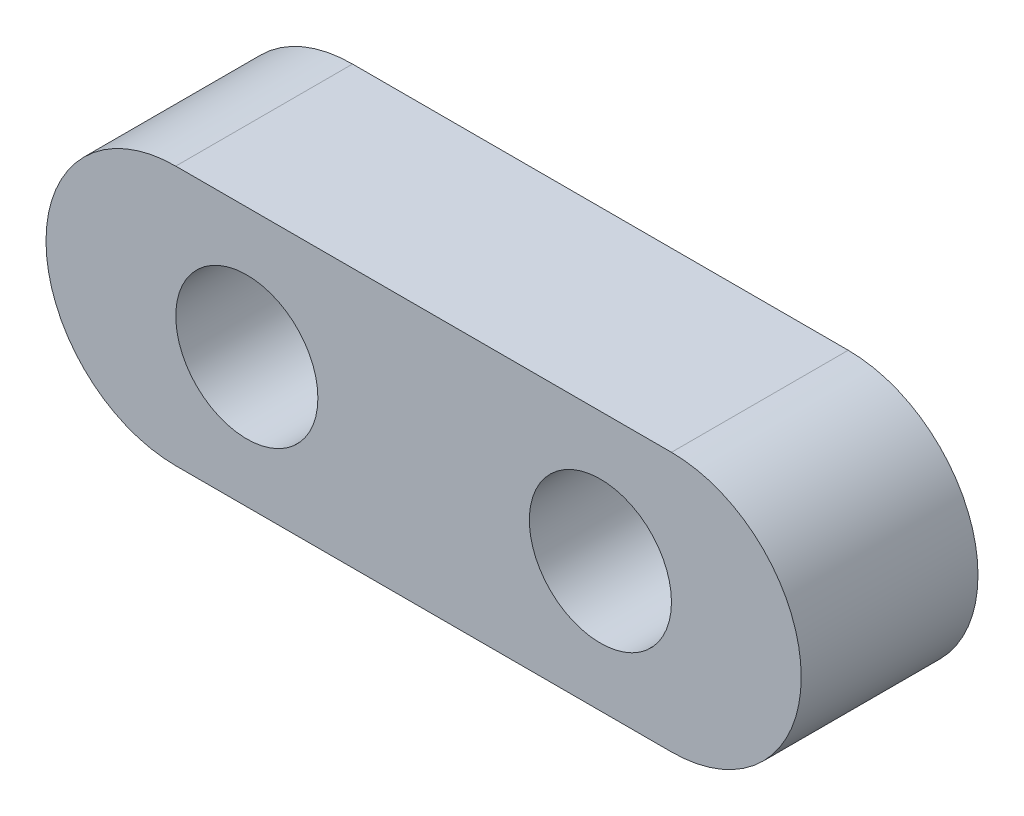
from build123d import *

# Parameters (mm, degrees)
BOSS_EXTRUDE1_DEPTH    = 6.35
F_10_CLEARANCE_HOLE1_D = 5.1054


with BuildPart() as part:
    # Sketch1 → Boss-Extrude1 (new body)
    with BuildSketch(Plane.XY):
        with BuildLine():
            Line((8.9027, -4.6609), (-8.9027, -4.6609))
            ThreePointArc((-8.9027, -4.6609), (-13.5636, 0), (-8.9027, 4.6609))
            Line((-8.9027, 4.6609), (8.9027, 4.6609))
            ThreePointArc((8.9027, 4.6609), (13.5636, 0), (8.9027, -4.6609))
        make_face()
    extrude(amount=BOSS_EXTRUDE1_DEPTH)

    # #10 Clearance Hole1 (through all)
    with Locations(Plane.XY.offset(6.35)):
        with Locations((-6.35, 0), (6.35, 0)):
            Hole(F_10_CLEARANCE_HOLE1_D / 2)


solid = part.part
